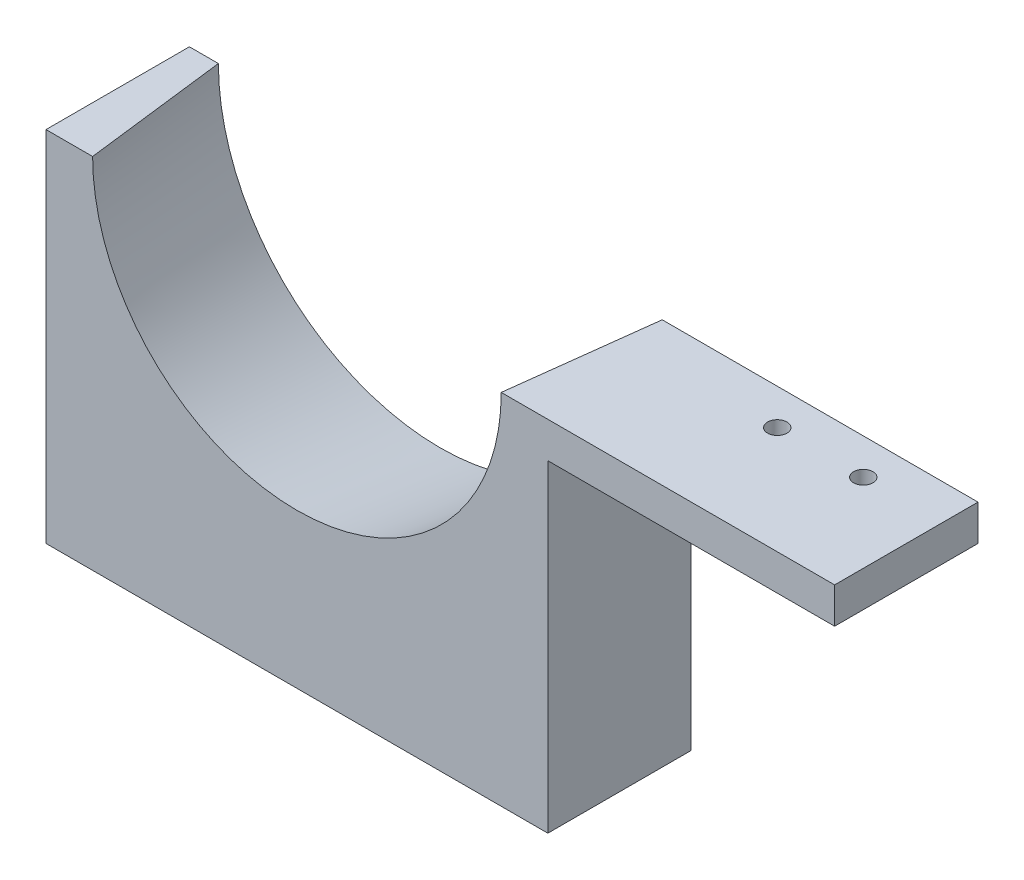
from build123d import *

# Parameters (mm, degrees)
SKETCH1_W           = 40
SKETCH1_H           = 5
BOSS_EXTRUDE1_DEPTH = 20
SKETCH2_R           = 28.5
CUT_EXTRUDE1_DEPTH  = 21
CUT_EXTRUDE1_TAPER  = -7
SKETCH3_R           = 1.35
CUT_EXTRUDE2_DEPTH  = 6.0000001


with BuildPart() as part:
    # Sketch1 → Boss-Extrude1 (new body)
    with BuildSketch(Plane.XY):
        with Locations((-20, -2.5)):
            Rectangle(SKETCH1_W, SKETCH1_H)
        Polygon((-40, -5), (-40, 0), (-110, 0), (-110, -50), (-40, -50), align=None)
    extrude(amount=BOSS_EXTRUDE1_DEPTH)

    # Sketch2 → Cut-Extrude1 (cut, through all)
    with BuildSketch(Plane.XY.offset(20)):
        with Locations((-75, 0)):
            Circle(SKETCH2_R)
    extrude(amount=-CUT_EXTRUDE1_DEPTH, taper=CUT_EXTRUDE1_TAPER, mode=Mode.SUBTRACT)

    # Sketch3 → Cut-Extrude2 (cut, through all)
    with BuildSketch(Plane.XZ.offset(5)):
        with Locations((-23, 5)):
            Circle(SKETCH3_R)
        with Locations((-11, 5)):
            Circle(SKETCH3_R)
    extrude(amount=-CUT_EXTRUDE2_DEPTH, mode=Mode.SUBTRACT)


solid = part.part
